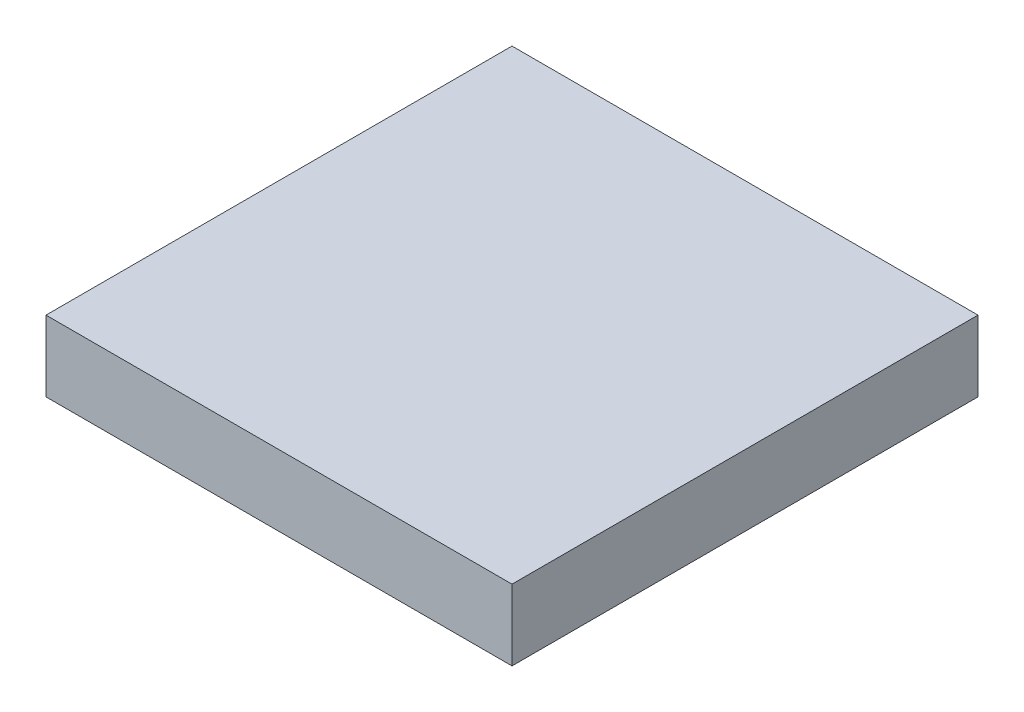
from build123d import *

# Parameters (mm, degrees)
SKETCH1_W           = 10
SKETCH1_H           = 10
BOSS_EXTRUDE1_DEPTH = 1.52


with BuildPart() as part:
    # Sketch1 → Boss-Extrude1 (new body)
    with BuildSketch(Plane(origin=(0, 0, 0), x_dir=(1, 0, 0), z_dir=(0, 1, 0))):
        Rectangle(SKETCH1_W, SKETCH1_H)
    extrude(amount=BOSS_EXTRUDE1_DEPTH)


solid = part.part
